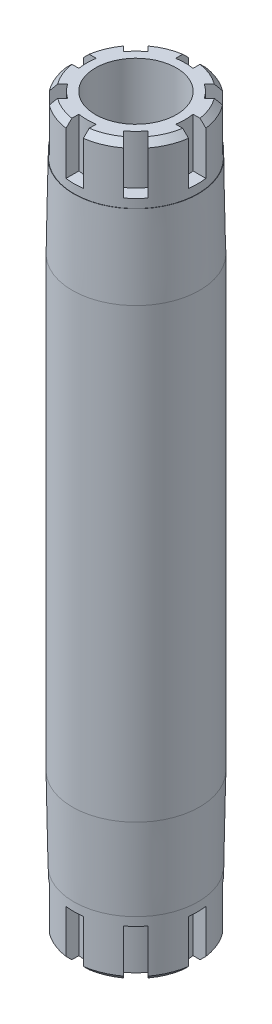
from build123d import *

# Parameters (mm, degrees)
ESQUISSE1_R                  = 11
ESQUISSE1_R_2                = 7
EXTRUSION1_DEPTH             = 63
CHANFREIN1_SIZE              = 1
ENL_V_MAT_EXTRU_1_DEPTH      = 8.5
R_P_TITION_CIRCULAIRE1_COUNT = 8
SYM_TRIE1_COPY_1_DEPTH       = 8.5
SYM_TRIE1_COPY_2_DEPTH       = 8.5
SYM_TRIE1_COPY_3_DEPTH       = 8.5
SYM_TRIE1_COPY_4_DEPTH       = 8.5
SYM_TRIE1_COPY_5_DEPTH       = 8.5
SYM_TRIE1_COPY_6_DEPTH       = 8.5
SYM_TRIE1_COPY_7_DEPTH       = 8.5


with BuildPart() as part:
    # Esquisse1 → Extrusion1 (new body, symmetric)
    with BuildSketch(Plane(origin=(0, 0, 0), x_dir=(1, 0, 0), z_dir=(0, 1, 0))):
        with Locations(Location((0, 0, 0), (0, 0, 270))):  # turned: the seam where the file's is
            Circle(ESQUISSE1_R)
        with Locations(Location((0, 0, 0), (0, 0, 270))):  # turned: the seam where the file's is
            Circle(ESQUISSE1_R_2, mode=Mode.SUBTRACT)
    extrude(amount=EXTRUSION1_DEPTH, both=True)

    # Esquisse3 → Enlèvement de matière-Révolution2 (revolve, cut)
    with BuildSketch(Plane.XY, mode=Mode.PRIVATE) as enl_vement_de_mati_re_r_volution2_sk:
        Polygon((10.7, 63), (10.7, 53), (10.75, 53), (11, 38.677509592), (11, 63), align=None)
        Polygon((11, -63), (10.7, -63), (10.7, -53), (10.75, -53), (11, -38.677509592), align=None)
    revolve(enl_vement_de_mati_re_r_volution2_sk.sketch.rotate(Axis((0, 68.024691358, 0), (0, -1, 0)), 90), axis=Axis((0, 68.024691358, 0), (0, -1, 0)), mode=Mode.SUBTRACT)  # turned: the seam where the file's is

    # Chanfrein1
    chanfrein1_edges = [part.edges().sort_by_distance(p)[0] for p in [
        (0, 63, -10.7),
        (0, -63, -10.7),
    ]]
    chamfer(chanfrein1_edges, length=CHANFREIN1_SIZE)

    # Esquisse4 → Enlèv. mat.-Extru.1 (cut)
    with BuildSketch(Plane(origin=(0, 63, 0), x_dir=(-1, 0, 0), z_dir=(0, 1, 0))):
        with BuildLine():
            Line((1.5, -10.594338111), (1.5, -8.366600265))
            ThreePointArc((1.5, -8.366600265), (0, -8.5), (-1.5, -8.366600265))
            Line((-1.5, -8.366600265), (-1.5, -10.594338111))
            ThreePointArc((-1.5, -10.594338111), (0, -10.7), (1.5, -10.594338111))
        make_face()
    enl_v_mat_extru_1 = extrude(amount=-ENL_V_MAT_EXTRU_1_DEPTH, mode=Mode.SUBTRACT)

    # Répétition circulaire1: Enlèv. mat.-Extru.1 ×8 about axis
    r_p_tition_circulaire1_axis = Axis((0, 0, 0), (0, 1, 0))
    for i in range(1, R_P_TITION_CIRCULAIRE1_COUNT):
        add(enl_v_mat_extru_1.rotate(r_p_tition_circulaire1_axis, i * 360 / R_P_TITION_CIRCULAIRE1_COUNT), mode=Mode.SUBTRACT)

    # Symétrie1: Enlèv. mat.-Extru.1 across plane
    add(enl_v_mat_extru_1.mirror(Plane.ZX), mode=Mode.SUBTRACT)

    # Symétrie1 copy 1 sketch → Symétrie1 copy 1 (cut)
    with BuildSketch(Plane(origin=(0, -63, 0), x_dir=(-0.707106781, 0, 0.707106781), z_dir=(0, -1, 0))):
        with BuildLine():
            Line((1.5, 10.594338111), (1.5, 8.366600265))
            ThreePointArc((1.5, 8.366600265), (0, 8.5), (-1.5, 8.366600265))
            Line((-1.5, 8.366600265), (-1.5, 10.594338111))
            ThreePointArc((-1.5, 10.594338111), (0, 10.7), (1.5, 10.594338111))
        make_face()
    extrude(amount=-SYM_TRIE1_COPY_1_DEPTH, mode=Mode.SUBTRACT)

    # Symétrie1 copy 2 sketch → Symétrie1 copy 2 (cut)
    with BuildSketch(Plane(origin=(0, -63, 0), x_dir=(0, 0, 1), z_dir=(0, -1, 0))):
        with BuildLine():
            Line((1.5, 10.594338111), (1.5, 8.366600265))
            ThreePointArc((1.5, 8.366600265), (0, 8.5), (-1.5, 8.366600265))
            Line((-1.5, 8.366600265), (-1.5, 10.594338111))
            ThreePointArc((-1.5, 10.594338111), (0, 10.7), (1.5, 10.594338111))
        make_face()
    extrude(amount=-SYM_TRIE1_COPY_2_DEPTH, mode=Mode.SUBTRACT)

    # Symétrie1 copy 3 sketch → Symétrie1 copy 3 (cut)
    with BuildSketch(Plane(origin=(0, -63, 0), x_dir=(0.707106781, 0, 0.707106781), z_dir=(0, -1, 0))):
        with BuildLine():
            Line((1.5, 10.594338111), (1.5, 8.366600265))
            ThreePointArc((1.5, 8.366600265), (0, 8.5), (-1.5, 8.366600265))
            Line((-1.5, 8.366600265), (-1.5, 10.594338111))
            ThreePointArc((-1.5, 10.594338111), (0, 10.7), (1.5, 10.594338111))
        make_face()
    extrude(amount=-SYM_TRIE1_COPY_3_DEPTH, mode=Mode.SUBTRACT)

    # Symétrie1 copy 4 sketch → Symétrie1 copy 4 (cut)
    with BuildSketch(Plane.XZ.offset(63)):
        with BuildLine():
            Line((1.5, 10.594338111), (1.5, 8.366600265))
            ThreePointArc((1.5, 8.366600265), (0, 8.5), (-1.5, 8.366600265))
            Line((-1.5, 8.366600265), (-1.5, 10.594338111))
            ThreePointArc((-1.5, 10.594338111), (0, 10.7), (1.5, 10.594338111))
        make_face()
    extrude(amount=-SYM_TRIE1_COPY_4_DEPTH, mode=Mode.SUBTRACT)

    # Symétrie1 copy 5 sketch → Symétrie1 copy 5 (cut)
    with BuildSketch(Plane(origin=(0, -63, 0), x_dir=(0.707106781, 0, -0.707106781), z_dir=(0, -1, 0))):
        with BuildLine():
            Line((1.5, 10.594338111), (1.5, 8.366600265))
            ThreePointArc((1.5, 8.366600265), (0, 8.5), (-1.5, 8.366600265))
            Line((-1.5, 8.366600265), (-1.5, 10.594338111))
            ThreePointArc((-1.5, 10.594338111), (0, 10.7), (1.5, 10.594338111))
        make_face()
    extrude(amount=-SYM_TRIE1_COPY_5_DEPTH, mode=Mode.SUBTRACT)

    # Symétrie1 copy 6 sketch → Symétrie1 copy 6 (cut)
    with BuildSketch(Plane(origin=(0, -63, 0), x_dir=(0, 0, -1), z_dir=(0, -1, 0))):
        with BuildLine():
            Line((1.5, 10.594338111), (1.5, 8.366600265))
            ThreePointArc((1.5, 8.366600265), (0, 8.5), (-1.5, 8.366600265))
            Line((-1.5, 8.366600265), (-1.5, 10.594338111))
            ThreePointArc((-1.5, 10.594338111), (0, 10.7), (1.5, 10.594338111))
        make_face()
    extrude(amount=-SYM_TRIE1_COPY_6_DEPTH, mode=Mode.SUBTRACT)

    # Symétrie1 copy 7 sketch → Symétrie1 copy 7 (cut)
    with BuildSketch(Plane(origin=(0, -63, 0), x_dir=(-0.707106781, 0, -0.707106781), z_dir=(0, -1, 0))):
        with BuildLine():
            Line((1.5, 10.594338111), (1.5, 8.366600265))
            ThreePointArc((1.5, 8.366600265), (0, 8.5), (-1.5, 8.366600265))
            Line((-1.5, 8.366600265), (-1.5, 10.594338111))
            ThreePointArc((-1.5, 10.594338111), (0, 10.7), (1.5, 10.594338111))
        make_face()
    extrude(amount=-SYM_TRIE1_COPY_7_DEPTH, mode=Mode.SUBTRACT)


solid = part.part
